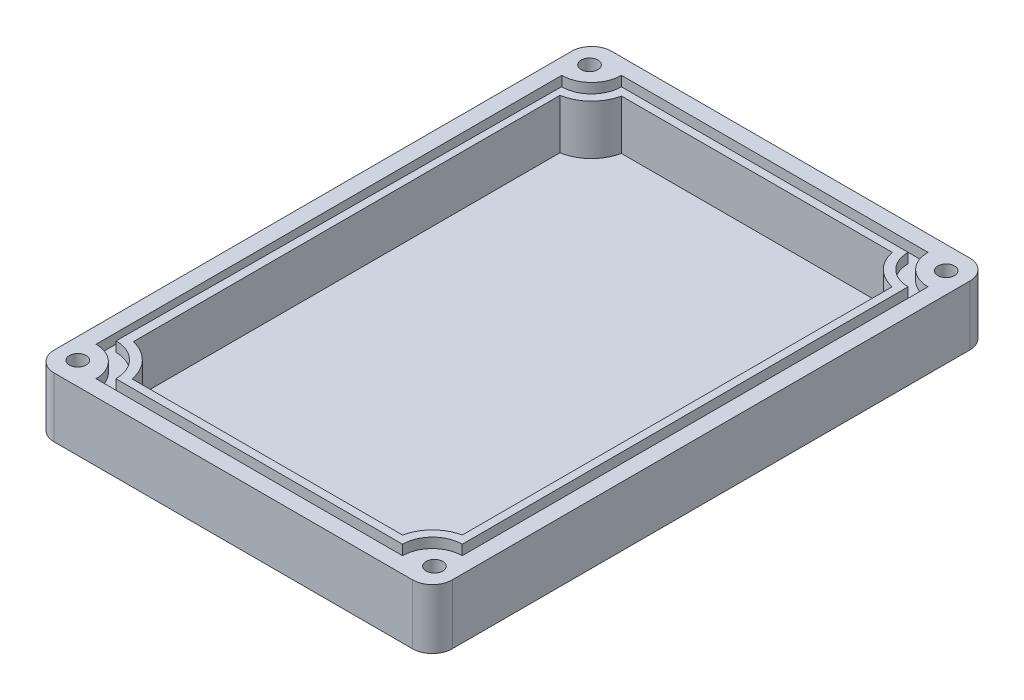
from build123d import *

# Parameters (mm, degrees)
BASE_W              = 100
BASE_H              = 140
BOTTOM_DEPTH        = 2.5
WALL_W              = 100
WALL_H              = 140
WALL_W_2            = 92
WALL_H_2            = 132
WALLS_DEPTH         = 12.5
MAINFILLET_R        = 5
DRILLHOLES_R        = 2.1
DRILLING_DEPTH      = 45
SKETCH8_R           = 3
CUT_EXTRUDE2_DEPTH  = 2.5
BOSS_EXTRUDE1_DEPTH = 12.5
BOSS_EXTRUDE2_DEPTH = 10


with BuildPart() as part:
    # Base → Bottom (new body)
    with BuildSketch(Plane(origin=(0, 0, 0), x_dir=(1, 0, 0), z_dir=(0, 1, 0))):
        Rectangle(BASE_W, BASE_H)
    extrude(amount=-BOTTOM_DEPTH)

    # Wall → Walls (add)
    with BuildSketch(Plane(origin=(0, 0, 0), x_dir=(1, 0, 0), z_dir=(0, 1, 0))):
        Rectangle(WALL_W, WALL_H)
        Rectangle(WALL_W_2, WALL_H_2, mode=Mode.SUBTRACT)
        with BuildLine():
            Line((-46, -58.5), (-46, -66))
            Line((-46, -66), (-38.5, -66))
            ThreePointArc((-38.5, -66), (-40.696699141, -60.696699141), (-46, -58.5))
        make_face()
        with BuildLine():
            ThreePointArc((46, -58.5), (40.696699141, -60.696699141), (38.5, -66))
            Line((38.5, -66), (46, -66))
            Line((46, -66), (46, -58.5))
        make_face()
        with BuildLine():
            Line((-46, 66), (-46, 58.5))
            ThreePointArc((-46, 58.5), (-40.696699141, 60.696699141), (-38.5, 66))
            Line((-38.5, 66), (-46, 66))
        make_face()
        with BuildLine():
            Line((46, 66), (38.5, 66))
            ThreePointArc((38.5, 66), (40.696699141, 60.696699141), (46, 58.5))
            Line((46, 58.5), (46, 66))
        make_face()
    extrude(amount=WALLS_DEPTH)

    # MainFillet
    mainfillet_edges = [part.edges().sort_by_distance(p)[0] for p in [
        (50, 5, -70),
        (50, 5, 70),
        (-50, 5, 70),
        (-50, 5, -70),
    ]]
    fillet(mainfillet_edges, radius=MAINFILLET_R)

    # DrillHoles → Drilling (cut)
    with BuildSketch(Plane(origin=(0, 12.5, 0), x_dir=(-1, 0, 0), z_dir=(0, -1, 0))):
        with Locations((44.79923541, 64.27716385)):
            Circle(DRILLHOLES_R)
        with Locations((44.79923541, -64.27716385)):
            Circle(DRILLHOLES_R)
        with Locations((-44.79923541, -64.27716385)):
            Circle(DRILLHOLES_R)
        with Locations((-44.79923541, 64.27716385)):
            Circle(DRILLHOLES_R)
    extrude(amount=DRILLING_DEPTH, mode=Mode.SUBTRACT)

    # Sketch8 → Cut-Extrude2 (cut)
    with BuildSketch(Plane(origin=(0, -2.5, 0), x_dir=(1, 0, 0), z_dir=(0, 1, 0))):
        with Locations((-44.79923541, 64.27716385)):
            Circle(SKETCH8_R)
        with Locations((44.79923541, 64.27716385)):
            Circle(SKETCH8_R)
        with Locations((-44.79923541, -64.27716385)):
            Circle(SKETCH8_R)
        with Locations((44.79923541, -64.27716385)):
            Circle(SKETCH8_R)
    extrude(amount=CUT_EXTRUDE2_DEPTH, mode=Mode.SUBTRACT)

    # Extrusion → Boss-Extrude1 (add)
    with BuildSketch(Plane(origin=(0, 12.5, 0), x_dir=(-1, 0, 0), z_dir=(0, -1, 0))):
        with BuildLine():
            Line((44.208318845, -55.242571154), (43.54473793, 56.000133433))
            ThreePointArc((43.54473793, 56.000133433), (38.212540046, 58.180905412), (36, 63.5))
            Line((36, 63.5), (-36, 63.5))
            ThreePointArc((-36, 63.5), (-38.196699141, 58.196699141), (-43.5, 56))
            Line((-43.5, 56), (-43.5, -56))
            ThreePointArc((-43.5, -56), (-38.196699141, -58.196699141), (-36, -63.5))
            Line((-36, -63.5), (36, -63.5))
            ThreePointArc((36, -63.5), (38.401198888, -57.678453182), (44.208318845, -55.242571154))
        make_face()
        with BuildLine():
            Line((41.876528387, 53.928461988), (41.876528387, -53.242571154))
            ThreePointArc((41.876528387, -53.242571154), (36.675168704, -56.193062448), (33.919092643, -61.5))
            Line((33.919092643, -61.5), (-34, -61.5))
            ThreePointArc((-34, -61.5), (-36.635234891, -56.635234891), (-41.5, -54))
            Line((-41.5, -54), (-41.5, 54))
            ThreePointArc((-41.5, 54), (-36.635234891, 56.635234891), (-34, 61.5))
            Line((-34, 61.5), (34, 61.5))
            ThreePointArc((34, 61.5), (36.772076684, 56.501068092), (41.876528387, 53.928461988))
        make_face(mode=Mode.SUBTRACT)
    extrude(amount=BOSS_EXTRUDE1_DEPTH)

    # Gasket → Boss-Extrude2 (add)
    with BuildSketch(Plane(origin=(0, 0, 0), x_dir=(1, 0, 0), z_dir=(0, 1, 0))):
        with BuildLine():
            Line((-38.5, 66), (38.5, 66))
            ThreePointArc((38.5, 66), (40.696699141, 60.696699141), (46, 58.5))
            Line((46, 58.5), (46, -58.5))
            ThreePointArc((46, -58.5), (40.696699141, -60.696699141), (38.5, -66))
            Line((38.5, -66), (-38.5, -66))
            ThreePointArc((-38.5, -66), (-40.696699141, -60.696699141), (-46, -58.5))
            Line((-46, -58.5), (-46, 58.5))
            ThreePointArc((-46, 58.5), (-40.696699141, 60.696699141), (-38.5, 66))
        make_face()
        with BuildLine():
            Line((-36, -63.5), (36, -63.5))
            ThreePointArc((36, -63.5), (38.196699141, -58.196699141), (43.5, -56))
            Line((43.5, -56), (43.5, 56))
            ThreePointArc((43.5, 56), (38.196699141, 58.196699141), (36, 63.5))
            Line((36, 63.5), (-36, 63.5))
            ThreePointArc((-36, 63.5), (-38.212540046, 58.180905412), (-43.54473793, 56.000133433))
            Line((-43.54473793, 56.000133433), (-44.208318845, -55.242571154))
            ThreePointArc((-44.208318845, -55.242571154), (-38.401198888, -57.678453182), (-36, -63.5))
        make_face(mode=Mode.SUBTRACT)
    extrude(amount=BOSS_EXTRUDE2_DEPTH)


solid = part.part
